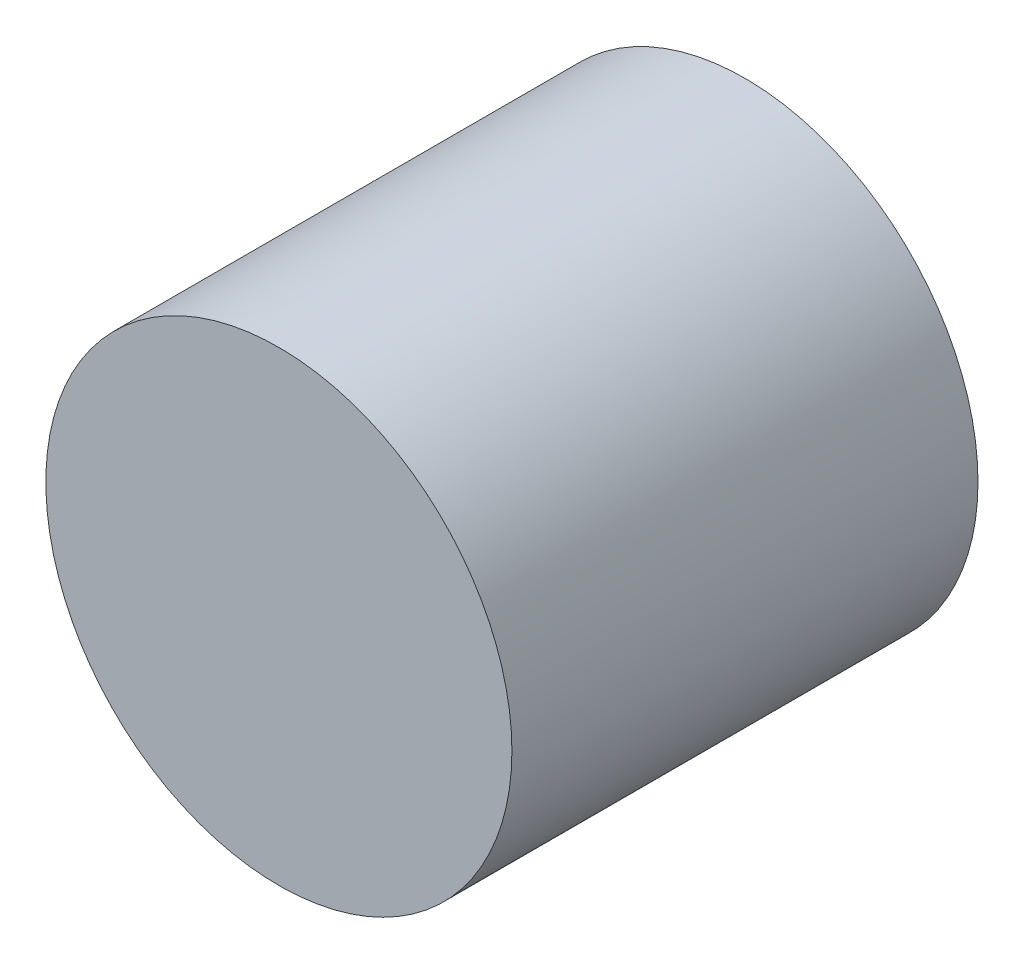
from build123d import *

# Parameters (mm, degrees)
ESQUISSE1_R        = 50
BOSS_EXTRU_1_DEPTH = 100


with BuildPart() as part:
    # Esquisse1 → Boss.-Extru.1 (new body)
    with BuildSketch(Plane.XY):
        Circle(ESQUISSE1_R)
    extrude(amount=BOSS_EXTRU_1_DEPTH)


solid = part.part
